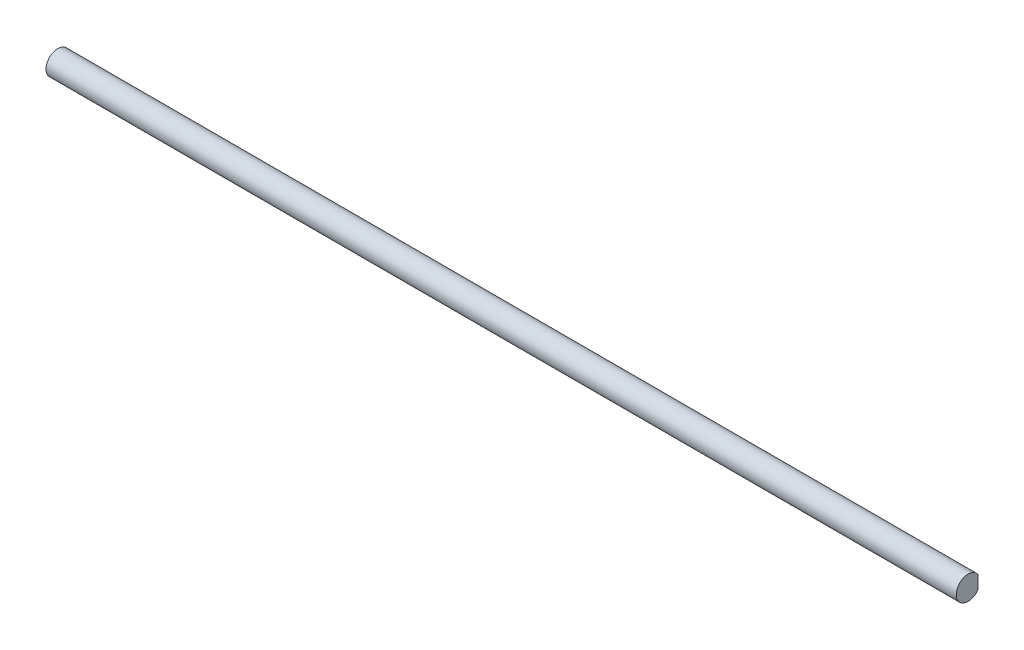
from build123d import *

# Parameters (mm, degrees)
SKETCH_1_R          = 6
EXTRUDE_1_DEPTH     = 460
SKETCH_2_W          = 15.5
SKETCH_2_H          = 1
CUT_EXTRUDE_1_DEPTH = 200
SKETCH_4_W          = 16.5
SKETCH_4_H          = 1
CUT_EXTRUDE_2_DEPTH = 200


with BuildPart() as part:
    # 草图1 → 凸台-拉伸1 (new body)
    with BuildSketch(Plane(origin=(0, 0, 0), x_dir=(0, 0, -1), z_dir=(1, 0, 0))):
        Circle(SKETCH_1_R)
    extrude(amount=EXTRUDE_1_DEPTH)

    # 草图2 → 切除-拉伸1 (cut, symmetric)
    with BuildSketch(Plane(origin=(0, 0, 0), x_dir=(1, 0, 0), z_dir=(0, 1, 0))):
        with Locations((7.75, 5.5)):
            Rectangle(SKETCH_2_W, SKETCH_2_H)
    cut_extrude_1 = extrude(amount=CUT_EXTRUDE_1_DEPTH, both=True, mode=Mode.SUBTRACT)

    # 镜向1: 切除-拉伸1 across plane
    add(cut_extrude_1.mirror(Plane.ZY.offset(-230)), mode=Mode.SUBTRACT)

    # 草图4 → 切除-拉伸2 (cut, symmetric)
    with BuildSketch(Plane(origin=(0, 0, 0), x_dir=(1, 0, 0), z_dir=(0, 1, 0))):
        with Locations((112.25, 5.5)):
            Rectangle(SKETCH_4_W, SKETCH_4_H)
    extrude(amount=CUT_EXTRUDE_2_DEPTH, both=True, mode=Mode.SUBTRACT)


solid = part.part
